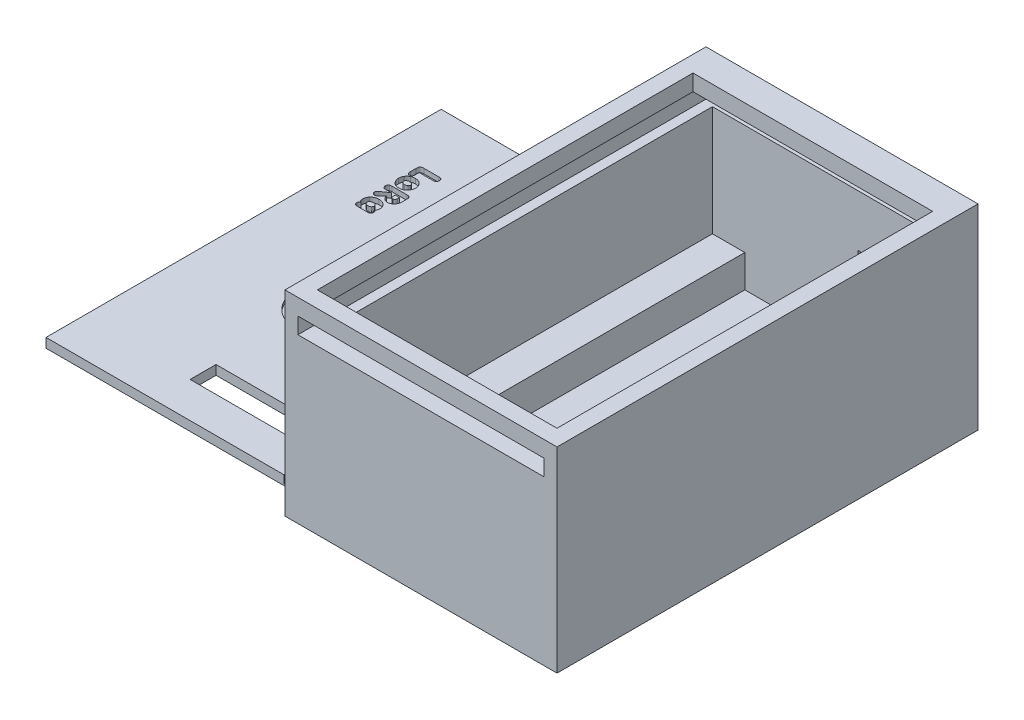
from build123d import *

# Parameters (mm, degrees)
ESQUISSE2_W              = 32
ESQUISSE2_H              = 55
BOSS_EXTRU_1_DEPTH       = 3
ESQUISSE3_W              = 55
ESQUISSE3_H              = 30
BOSS_EXTRU_2_DEPTH       = 3
ESQUISSE5_W              = 55
ESQUISSE5_H              = 30
BOSS_EXTRU_3_DEPTH       = 3
ESQUISSE6_W              = 38
ESQUISSE6_H              = 30
BOSS_EXTRU_4_DEPTH       = 3
ESQUISSE7_W              = 38
ESQUISSE7_H              = 30
BOSS_EXTRU_5_DEPTH       = 3
ESQUISSE8_W              = 3.5
ESQUISSE8_H              = 55
BOSS_EXTRU_6_DEPTH       = 5
ESQUISSE9_W              = 3.5
ESQUISSE9_H              = 55
BOSS_EXTRU_7_DEPTH       = 5
ESQUISSE12_W             = 32
ESQUISSE12_H             = 2.5
ENL_V_MAT_EXTRU_1_DEPTH  = 4
ESQUISSE13_W             = 38
ESQUISSE13_H             = 30
BOSS_EXTRU_8_DEPTH       = 2
ESQUISSE14_W             = 63
ESQUISSE14_H             = 30
BOSS_EXTRU_9_DEPTH       = 2
ESQUISSE15_W             = 40
ESQUISSE15_H             = 30
BOSS_EXTRU_10_DEPTH      = 2
ESQUISSE16_W             = 32
ESQUISSE16_H             = 2.5
ENL_V_MAT_EXTRU_2_DEPTH  = 2
ESQUISSE17_W             = 65
ESQUISSE17_H             = 30
BOSS_EXTRU_11_DEPTH      = 2
ESQUISSE18_W             = 60
ESQUISSE18_H             = 2.5
ENL_V_MAT_EXTRU_3_DEPTH  = 3
ESQUISSE19_W             = 60
ESQUISSE19_H             = 2.5
ENL_V_MAT_EXTRU_4_DEPTH  = 3
ESQUISSE20_W             = 38
ESQUISSE20_H             = 2.5
ENL_V_MAT_EXTRU_5_DEPTH  = 3
ESQUISSE22_W             = 4.144510242
ESQUISSE22_H             = 65
BOSS_EXTRU_12_DEPTH      = 0.5
ESQUISSE23_W             = 65
ESQUISSE23_H             = 2.45
BOSS_EXTRU_13_DEPTH      = 37.5
ESQUISSE24_W             = 37.5
ESQUISSE24_H             = 2.45
ENL_V_MAT_EXTRU_6_DEPTH  = 2
ESQUISSE25_W             = 4.144510242
ESQUISSE25_H             = 2
ENL_V_MAT_EXTRU_7_DEPTH  = 1.5
ESQUISSE26_W             = 42
ESQUISSE26_H             = 65
BOSS_EXTRU_14_DEPTH      = 0.5
ESQUISSE29_W             = 25
ESQUISSE29_H             = 5
BOSS_EXTRU_16_DEPTH      = 3.5
ESQUISSE31_W             = 2.5
ESQUISSE31_H             = 5
ENL_V_MAT_EXTRU_8_DEPTH  = 3.5
ESQUISSE33_W             = 11
ESQUISSE33_H             = 11
ENL_V_MAT_EXTRU_10_DEPTH = 6
ESQUISSE34_W             = 20
ESQUISSE34_H             = 4
ENL_V_MAT_EXTRU_12_DEPTH = 3.45
ESQUISSE36_R             = 5
ENL_V_MAT_EXTRU_13_DEPTH = 1.2
ESQUISSE38_W             = 32
ESQUISSE38_H             = 22
ENL_V_MAT_EXTRU_14_DEPTH = 2.5
ESQUISSE40_W             = 32
ESQUISSE40_H             = 27
ENL_V_MAT_EXTRU_15_DEPTH = 2.5
ESQUISSE42_W             = 60
ESQUISSE42_H             = 22
ENL_V_MAT_EXTRU_16_DEPTH = 2.5
ESQUISSE43_W             = 60
ESQUISSE43_H             = 22
ENL_V_MAT_EXTRU_17_DEPTH = 2.5
ESQUISSE44_W             = 3.5
ESQUISSE44_H             = 5
ENL_V_MAT_EXTRU_18_DEPTH = 5
ESQUISSE45_W             = 10
ESQUISSE45_H             = 5
ENL_V_MAT_EXTRU_19_DEPTH = 2.5
ESQUISSE47_W             = 63
ESQUISSE47_H             = 2.45
ENL_V_MAT_EXTRU_20_DEPTH = 2
ESQUISSE48_W             = 39.644510242
ESQUISSE48_H             = 2.45
ENL_V_MAT_EXTRU_21_DEPTH = 2
ESQUISSE49_W             = 81.644510242
ESQUISSE49_H             = 65
ENL_V_MAT_EXTRU_23_DEPTH = 0.25
ESQUISSE50_W             = 35.5
ESQUISSE50_H             = 61
ENL_V_MAT_EXTRU_24_DEPTH = 0.75
ESQUISSE53_W             = 2.5
ESQUISSE53_H             = 11
BOSS_EXTRU_17_DEPTH      = 1.5
ESQUISSE54_W             = 9.5
ESQUISSE54_H             = 2.5
BOSS_EXTRU_19_DEPTH      = 2
ESQUISSE55_W             = 60
ESQUISSE55_H             = 22
BOSS_EXTRU_20_DEPTH      = 1
ESQUISSE56_W             = 60
ESQUISSE56_H             = 17
BOSS_EXTRU_21_DEPTH      = 1
ESQUISSE57_W             = 2.5
ESQUISSE57_H             = 5
BOSS_EXTRU_22_DEPTH      = 3.5
ESQUISSE58_W             = 37
ESQUISSE58_H             = 2.5
BOSS_EXTRU_23_DEPTH      = 2
ESQUISSE59_W             = 61
ESQUISSE59_H             = 1.45
BOSS_EXTRU_24_DEPTH      = 1.25
ENL_V_MAT_EXTRU_27_DEPTH = 0.75


with BuildPart() as part:
    # Esquisse2 → Boss.-Extru.1 (new body)
    with BuildSketch(Plane(origin=(0, 0, 0), x_dir=(1, 0, 0), z_dir=(0, 1, 0))):
        with Locations((-55.470108058, 17.287934383)):
            Rectangle(ESQUISSE2_W, ESQUISSE2_H)
    extrude(amount=BOSS_EXTRU_1_DEPTH)

    # Esquisse3 → Boss.-Extru.2 (add)
    with BuildSketch(Plane.ZY.offset(71.470108058)):
        with Locations((-17.287934383, 15)):
            Rectangle(ESQUISSE3_W, ESQUISSE3_H)
    extrude(amount=BOSS_EXTRU_2_DEPTH)

    # Esquisse5 → Boss.-Extru.3 (add)
    with BuildSketch(Plane(origin=(-39.470108058, 0, 0), x_dir=(0, 0, -1), z_dir=(1, 0, 0))):
        with Locations((17.287934383, 15)):
            Rectangle(ESQUISSE5_W, ESQUISSE5_H)
    extrude(amount=BOSS_EXTRU_3_DEPTH)

    # Esquisse6 → Boss.-Extru.4 (add)
    with BuildSketch(Plane(origin=(0, 0, -44.787934383), x_dir=(-1, 0, 0), z_dir=(0, 0, -1))):
        with Locations((55.470108058, 15)):
            Rectangle(ESQUISSE6_W, ESQUISSE6_H)
    extrude(amount=BOSS_EXTRU_4_DEPTH)

    # Esquisse7 → Boss.-Extru.5 (add)
    with BuildSketch(Plane.XY.offset(10.212065617)):
        with Locations((-55.470108058, 15)):
            Rectangle(ESQUISSE7_W, ESQUISSE7_H)
    extrude(amount=BOSS_EXTRU_5_DEPTH)

    # Esquisse8 → Boss.-Extru.6 (add)
    with BuildSketch(Plane(origin=(0, 3, 0), x_dir=(1, 0, 0), z_dir=(0, 1, 0))):
        with Locations((-69.720108058, 17.287934383)):
            Rectangle(ESQUISSE8_W, ESQUISSE8_H)
    extrude(amount=BOSS_EXTRU_6_DEPTH)

    # Esquisse9 → Boss.-Extru.7 (add)
    with BuildSketch(Plane(origin=(0, 3, 0), x_dir=(1, 0, 0), z_dir=(0, 1, 0))):
        with Locations((-41.220108058, 17.287934383)):
            Rectangle(ESQUISSE9_W, ESQUISSE9_H)
    extrude(amount=BOSS_EXTRU_7_DEPTH)

    # Esquisse12 → Enlèv. mat.-Extru.1 (cut, through all)
    with BuildSketch(Plane(origin=(0, 0, 10.212065617), x_dir=(-1, 0, 0), z_dir=(0, 0, -1))):
        with Locations((55.470108058, 26.25)):
            Rectangle(ESQUISSE12_W, ESQUISSE12_H)
    extrude(amount=-ENL_V_MAT_EXTRU_1_DEPTH, mode=Mode.SUBTRACT)

    # Esquisse13 → Boss.-Extru.8 (add)
    with BuildSketch(Plane(origin=(0, 0, -47.787934383), x_dir=(-1, 0, 0), z_dir=(0, 0, -1))):
        with Locations((55.470108058, 15)):
            Rectangle(ESQUISSE13_W, ESQUISSE13_H)
    extrude(amount=BOSS_EXTRU_8_DEPTH)

    # Esquisse14 → Boss.-Extru.9 (add)
    with BuildSketch(Plane(origin=(-36.470108058, 0, 0), x_dir=(0, 0, -1), z_dir=(1, 0, 0))):
        with Locations((18.287934383, 15)):
            Rectangle(ESQUISSE14_W, ESQUISSE14_H)
    extrude(amount=BOSS_EXTRU_9_DEPTH)

    # Esquisse15 → Boss.-Extru.10 (add)
    with BuildSketch(Plane.XY.offset(13.212065617)):
        with Locations((-54.470108058, 15)):
            Rectangle(ESQUISSE15_W, ESQUISSE15_H)
    extrude(amount=BOSS_EXTRU_10_DEPTH)

    # Esquisse16 → Enlèv. mat.-Extru.2 (cut)
    with BuildSketch(Plane(origin=(0, 0, 13.212065617), x_dir=(-1, 0, 0), z_dir=(0, 0, -1))):
        with Locations((55.470108058, 26.25)):
            Rectangle(ESQUISSE16_W, ESQUISSE16_H)
    extrude(amount=-ENL_V_MAT_EXTRU_2_DEPTH, mode=Mode.SUBTRACT)

    # Esquisse17 → Boss.-Extru.11 (add)
    with BuildSketch(Plane.ZY.offset(74.470108058)):
        with Locations((-17.287934383, 15)):
            Rectangle(ESQUISSE17_W, ESQUISSE17_H)
    extrude(amount=BOSS_EXTRU_11_DEPTH)

    # Esquisse18 → Enlèv. mat.-Extru.3 (cut)
    with BuildSketch(Plane.ZY.offset(39.470108058)):
        with Locations((-14.787934383, 26.25)):
            Rectangle(ESQUISSE18_W, ESQUISSE18_H)
    extrude(amount=-ENL_V_MAT_EXTRU_3_DEPTH, mode=Mode.SUBTRACT)

    # Esquisse19 → Enlèv. mat.-Extru.4 (cut)
    with BuildSketch(Plane(origin=(-71.470108058, 0, 0), x_dir=(0, 0, -1), z_dir=(1, 0, 0))):
        with Locations((14.787934383, 26.25)):
            Rectangle(ESQUISSE19_W, ESQUISSE19_H)
    extrude(amount=-ENL_V_MAT_EXTRU_4_DEPTH, mode=Mode.SUBTRACT)

    # Esquisse20 → Enlèv. mat.-Extru.5 (cut)
    with BuildSketch(Plane.XY.offset(-44.787934383)):
        with Locations((-55.470108058, 26.25)):
            Rectangle(ESQUISSE20_W, ESQUISSE20_H)
    extrude(amount=-ENL_V_MAT_EXTRU_5_DEPTH, mode=Mode.SUBTRACT)



with BuildPart() as body_2:
    # Esquisse22 → Boss.-Extru.12 (new body)
    with BuildSketch(Plane.XZ):
        with Locations((-78.542363179, -17.287934383)):
            Rectangle(ESQUISSE22_W, ESQUISSE22_H)
    extrude(amount=BOSS_EXTRU_12_DEPTH)

    # Esquisse23 → Boss.-Extru.13 (add)
    with BuildSketch(Plane.ZY.offset(80.6146183)):
        with Locations((-17.287934383, 0.725)):
            Rectangle(ESQUISSE23_W, ESQUISSE23_H)
    extrude(amount=BOSS_EXTRU_13_DEPTH)

    # Esquisse24 → Enlèv. mat.-Extru.6 (cut)
    with BuildSketch(Plane.XY.offset(15.212065617)):
        with Locations((-99.3646183, 0.725)):
            Rectangle(ESQUISSE24_W, ESQUISSE24_H)
    extrude(amount=-ENL_V_MAT_EXTRU_6_DEPTH, mode=Mode.SUBTRACT)

    # Esquisse25 → Enlèv. mat.-Extru.7 (cut, through all)
    with BuildSketch(Plane(origin=(0, 0, 0), x_dir=(1, 0, 0), z_dir=(0, 1, 0))):
        with Locations((-78.542363179, -14.212065617)):
            Rectangle(ESQUISSE25_W, ESQUISSE25_H)
    extrude(amount=-ENL_V_MAT_EXTRU_7_DEPTH, mode=Mode.SUBTRACT)


with BuildPart() as part_1:
    add(part.part)

    add(body_2.part)  # Boss.-Extru.14 merges body 2
    # Esquisse26 → Boss.-Extru.14 (add, through all)
    with BuildSketch(Plane.XZ):
        with Locations((-55.470108058, -17.287934383)):
            Rectangle(ESQUISSE26_W, ESQUISSE26_H)
    extrude(amount=BOSS_EXTRU_14_DEPTH)

    # Esquisse29 → Boss.-Extru.16 (add)
    with BuildSketch(Plane(origin=(0, 0, 10.212065617), x_dir=(-1, 0, 0), z_dir=(0, 0, -1))):
        with Locations((55.470108058, 5.5)):
            Rectangle(ESQUISSE29_W, ESQUISSE29_H)
    extrude(amount=BOSS_EXTRU_16_DEPTH)

    # Esquisse31 → Enlèv. mat.-Extru.8 (cut)
    with BuildSketch(Plane.ZY.offset(42.970108058)):
        with Locations((-43.537934383, 5.5)):
            Rectangle(ESQUISSE31_W, ESQUISSE31_H)
    extrude(amount=-ENL_V_MAT_EXTRU_8_DEPTH, mode=Mode.SUBTRACT)

    # Esquisse33 → Enlèv. mat.-Extru.10 (cut, through all)
    with BuildSketch(Plane.XY.offset(-44.787934383)):
        with Locations((-44.970108058, 13.5)):
            Rectangle(ESQUISSE33_W, ESQUISSE33_H)
    extrude(amount=-ENL_V_MAT_EXTRU_10_DEPTH, mode=Mode.SUBTRACT)

    # Esquisse34 → Enlèv. mat.-Extru.12 (cut, through all)
    with BuildSketch(Plane(origin=(0, 1.95, 0), x_dir=(1, 0, 0), z_dir=(0, 1, 0))):
        with Locations((-90.6146183, -3.708093447)):
            Rectangle(ESQUISSE34_W, ESQUISSE34_H)
    extrude(amount=-ENL_V_MAT_EXTRU_12_DEPTH, mode=Mode.SUBTRACT)

    # Esquisse36 → Enlèv. mat.-Extru.13 (cut)
    with BuildSketch(Plane(origin=(-2.005651667, 1.95, -1.300827816), x_dir=(1, 0, 0), z_dir=(0, 1, 0))):
        with Locations((-97.347627811, 12.937673095)):
            Circle(ESQUISSE36_R)
    extrude(amount=-ENL_V_MAT_EXTRU_13_DEPTH, mode=Mode.SUBTRACT)

    # Esquisse38 → Enlèv. mat.-Extru.14 (cut)
    with BuildSketch(Plane(origin=(0, 0, 10.212065617), x_dir=(-1, 0, 0), z_dir=(0, 0, -1))):
        with Locations((55.470108058, 19)):
            Rectangle(ESQUISSE38_W, ESQUISSE38_H)
    extrude(amount=-ENL_V_MAT_EXTRU_14_DEPTH, mode=Mode.SUBTRACT)

    # Esquisse40 → Enlèv. mat.-Extru.15 (cut)
    with BuildSketch(Plane.XY.offset(-44.787934383)):
        with Locations((-55.470108058, 16.5)):
            Rectangle(ESQUISSE40_W, ESQUISSE40_H)
    extrude(amount=-ENL_V_MAT_EXTRU_15_DEPTH, mode=Mode.SUBTRACT)

    # Esquisse42 → Enlèv. mat.-Extru.16 (cut)
    with BuildSketch(Plane(origin=(-71.470108058, 0, 0), x_dir=(0, 0, -1), z_dir=(1, 0, 0))):
        with Locations((17.287934383, 19)):
            Rectangle(ESQUISSE42_W, ESQUISSE42_H)
    extrude(amount=-ENL_V_MAT_EXTRU_16_DEPTH, mode=Mode.SUBTRACT)

    # Esquisse43 → Enlèv. mat.-Extru.17 (cut)
    with BuildSketch(Plane.ZY.offset(39.470108058)):
        with Locations((-17.287934383, 19)):
            Rectangle(ESQUISSE43_W, ESQUISSE43_H)
    extrude(amount=-ENL_V_MAT_EXTRU_17_DEPTH, mode=Mode.SUBTRACT)

    # Esquisse44 → Enlèv. mat.-Extru.18 (cut)
    with BuildSketch(Plane(origin=(0, 0, -42.287934383), x_dir=(-1, 0, 0), z_dir=(0, 0, -1))):
        with Locations((41.220108058, 5.5)):
            Rectangle(ESQUISSE44_W, ESQUISSE44_H)
    extrude(amount=-ENL_V_MAT_EXTRU_18_DEPTH, mode=Mode.SUBTRACT)

    # Esquisse45 → Enlèv. mat.-Extru.19 (cut)
    with BuildSketch(Plane.ZY.offset(39.470108058)):
        with Locations((-42.287934383, 5.5)):
            Rectangle(ESQUISSE45_W, ESQUISSE45_H)
    extrude(amount=-ENL_V_MAT_EXTRU_19_DEPTH, mode=Mode.SUBTRACT)

    # Esquisse47 → Enlèv. mat.-Extru.20 (cut)
    with BuildSketch(Plane.ZY.offset(118.1146183)):
        with Locations((-18.287934383, 0.725)):
            Rectangle(ESQUISSE47_W, ESQUISSE47_H)
    extrude(amount=-ENL_V_MAT_EXTRU_20_DEPTH, mode=Mode.SUBTRACT)

    # Esquisse48 → Enlèv. mat.-Extru.21 (cut)
    with BuildSketch(Plane.XY.offset(13.212065617)):
        with Locations((-96.292363179, 0.725)):
            Rectangle(ESQUISSE48_W, ESQUISSE48_H)
    extrude(amount=-ENL_V_MAT_EXTRU_21_DEPTH, mode=Mode.SUBTRACT)

    # Esquisse49 → Enlèv. mat.-Extru.23 (cut)
    with BuildSketch(Plane.XZ.offset(0.5)):
        with Locations((-75.292363179, -17.287934383)):
            Rectangle(ESQUISSE49_W, ESQUISSE49_H)
    extrude(amount=-ENL_V_MAT_EXTRU_23_DEPTH, mode=Mode.SUBTRACT)

    # Esquisse50 → Enlèv. mat.-Extru.24 (cut)
    with BuildSketch(Plane(origin=(0, 1.95, 0), x_dir=(1, 0, 0), z_dir=(0, 1, 0))):
        with Locations((-98.3646183, 19.287934383)):
            Rectangle(ESQUISSE50_W, ESQUISSE50_H)
    extrude(amount=-ENL_V_MAT_EXTRU_24_DEPTH, mode=Mode.SUBTRACT)

    # Esquisse53 → Boss.-Extru.17 (add)
    with BuildSketch(Plane.ZY.offset(39.470108058)):
        with Locations((-48.537934383, 13.5)):
            Rectangle(ESQUISSE53_W, ESQUISSE53_H)
    extrude(amount=BOSS_EXTRU_17_DEPTH)

    # Esquisse54 → Boss.-Extru.19 (add)
    with BuildSketch(Plane.XZ.offset(-19)):
        with Locations((-45.720108058, -48.537934383)):
            Rectangle(ESQUISSE54_W, ESQUISSE54_H)
    extrude(amount=BOSS_EXTRU_19_DEPTH)

    # Esquisse55 → Boss.-Extru.20 (add)
    with BuildSketch(Plane.ZY.offset(36.970108058)):
        with Locations((-17.287934383, 14)):
            Rectangle(ESQUISSE55_W, ESQUISSE55_H)
    extrude(amount=BOSS_EXTRU_20_DEPTH)

    # Esquisse56 → Boss.-Extru.21 (add)
    with BuildSketch(Plane(origin=(-73.970108058, 0, 0), x_dir=(0, 0, -1), z_dir=(1, 0, 0))):
        with Locations((17.287934383, 16.5)):
            Rectangle(ESQUISSE56_W, ESQUISSE56_H)
    extrude(amount=BOSS_EXTRU_21_DEPTH)

    # Esquisse57 → Boss.-Extru.22 (add)
    with BuildSketch(Plane(origin=(-71.470108058, 0, 0), x_dir=(0, 0, -1), z_dir=(1, 0, 0))):
        with Locations((46.037934383, 5.5)):
            Rectangle(ESQUISSE57_W, ESQUISSE57_H)
    extrude(amount=BOSS_EXTRU_22_DEPTH)

    # Esquisse58 → Boss.-Extru.23 (add)
    with BuildSketch(Plane.XY.offset(-47.287934383)):
        with Locations((-55.470108058, 28.75)):
            Rectangle(ESQUISSE58_W, ESQUISSE58_H)
    extrude(amount=BOSS_EXTRU_23_DEPTH)

    # Esquisse59 → Boss.-Extru.24 (add)
    with BuildSketch(Plane.ZY.offset(116.1146183)):
        with Locations((-19.287934383, 0.475)):
            Rectangle(ESQUISSE59_W, ESQUISSE59_H)
    extrude(amount=BOSS_EXTRU_24_DEPTH)

    # Esquisse62 → Enlèv. mat.-Extru.27 (cut)
    with BuildSketch(Plane(origin=(0, 1.2, 0), x_dir=(1, 0, 0), z_dir=(0, 1, 0))):
        with BuildLine():
            Line((-110.60098691, 39.638707933), (-110.60098691, 39.0444371))
            add(Edge.make_bspline(
                [(-110.60098691, 39.0444371), (-110.601699377, 39.010618931), (-110.603019937, 38.947936782), (-110.612061779, 38.861258901), (-110.627214726, 38.788744217), (-110.645797125, 38.747928908), (-110.654216077, 38.7294371)],
                knots=[0, 0, 0, 0, 0.00010142, 0.000187982, 0.000261382, 0.000322183, 0.000322183, 0.000322183, 0.000322183], degree=3))
            add(Edge.make_bspline(
                [(-110.654216077, 38.7294371), (-110.664452385, 38.71163664), (-110.684180523, 38.677330329), (-110.720579985, 38.631953059), (-110.761473064, 38.594212332), (-110.807235748, 38.565488171), (-110.854151675, 38.542573429), (-110.902280797, 38.527841372), (-110.949719645, 38.516344758), (-110.981786673, 38.515486681), (-110.997653577, 38.5150621)],
                knots=[0, 0, 0, 0, 6.1527e-05, 0.000118579, 0.000173809, 0.000227609, 0.000280119, 0.000329927, 0.00037841, 0.000425896, 0.000425896, 0.000425896, 0.000425896], degree=3))
            add(Edge.make_bspline(
                [(-110.997653577, 38.5150621), (-111.013246752, 38.515910426), (-111.044941313, 38.517634726), (-111.092897033, 38.52726695), (-111.140978127, 38.544439934), (-111.189013988, 38.567529985), (-111.23532068, 38.597715971), (-111.275896019, 38.637328197), (-111.313491979, 38.682725962), (-111.332666309, 38.717880009), (-111.34254941, 38.7359996)],
                knots=[0, 0, 0, 0, 4.6809e-05, 9.5143e-05, 0.000146107, 0.00019959, 0.0002548, 0.000311022, 0.000369099, 0.000430876, 0.000430876, 0.000430876, 0.000430876], degree=3))
            add(Edge.make_bspline(
                [(-111.34254941, 38.7359996), (-111.350748978, 38.754743109), (-111.368951169, 38.796351761), (-111.382798262, 38.870413448), (-111.393565101, 38.959035056), (-111.394055418, 39.023482428), (-111.394320244, 39.058291267)],
                knots=[0, 0, 0, 0, 6.1202e-05, 0.000135863, 0.00022468, 0.000328992, 0.000328992, 0.000328992, 0.000328992], degree=3))
            Line((-111.394320244, 39.058291267), (-111.394320244, 39.9522496))
            add(Edge.make_bspline(
                [(-111.394320244, 39.9522496), (-111.394124373, 39.984336133), (-111.393760523, 40.043940178), (-111.38910407, 40.126289651), (-111.380263812, 40.194659147), (-111.369471319, 40.251898475), (-111.350354402, 40.301037927), (-111.326509385, 40.347620361), (-111.293708571, 40.391798121), (-111.255828575, 40.434275164), (-111.213354082, 40.472178942), (-111.169144439, 40.504888523), (-111.122752383, 40.529011711), (-111.073269807, 40.546944796), (-111.016007814, 40.5581418), (-110.947093046, 40.566770421), (-110.864278663, 40.571482882), (-110.804429152, 40.571846379), (-110.772341077, 40.572041267)],
                knots=[0, 0, 0, 0, 9.6261e-05, 0.000178815, 0.00024719, 0.000303108, 0.000352948, 0.000404806, 0.000459649, 0.000517478, 0.000575308, 0.000630151, 0.000682009, 0.000731598, 0.000787516, 0.000856614, 0.000939895, 0.001036156, 0.001036156, 0.001036156, 0.001036156], degree=3))
            Line((-110.772341077, 40.572041267), (-108.49442441, 40.572041267))
            add(Edge.make_bspline(
                [(-108.49442441, 40.572041267), (-108.458893301, 40.571471942), (-108.392499924, 40.570408102), (-108.300277181, 40.559453931), (-108.221663101, 40.542902566), (-108.176756986, 40.522909016), (-108.156091077, 40.513707933)],
                knots=[0, 0, 0, 0, 0.000106521, 0.000199044, 0.000278457, 0.000346159, 0.000346159, 0.000346159, 0.000346159], degree=3))
            add(Edge.make_bspline(
                [(-108.156091077, 40.513707933), (-108.140714592, 40.504426232), (-108.109536758, 40.485606367), (-108.067846373, 40.448691672), (-108.031349922, 40.404295665), (-107.999784787, 40.354453757), (-107.973425399, 40.30078831), (-107.954442628, 40.24469735), (-107.943077853, 40.18701386), (-107.941686005, 40.148202169), (-107.94098691, 40.128707933)],
                knots=[0, 0, 0, 0, 5.38e-05, 0.000109087, 0.000166037, 0.000225709, 0.000285713, 0.000344974, 0.000402891, 0.000461338, 0.000461338, 0.000461338, 0.000461338], degree=3))
            add(Edge.make_bspline(
                [(-107.94098691, 40.128707933), (-107.941855607, 40.105800623), (-107.943578086, 40.060379255), (-107.956545737, 39.993558243), (-107.976731222, 39.928651742), (-108.006104433, 39.868169171), (-108.03844453, 39.812779731), (-108.074243588, 39.766273653), (-108.112284035, 39.729149996), (-108.140914076, 39.711879349), (-108.154632744, 39.703603767)],
                knots=[0, 0, 0, 0, 6.8681e-05, 0.000136183, 0.00020352, 0.000272019, 0.000337421, 0.000395617, 0.000447715, 0.000495647, 0.000495647, 0.000495647, 0.000495647], degree=3))
            add(Edge.make_bspline(
                [(-108.154632744, 39.703603767), (-108.176737053, 39.69342604), (-108.223521791, 39.671884436), (-108.303219763, 39.652603302), (-108.393458634, 39.641242055), (-108.457196414, 39.639582382), (-108.490778577, 39.638707933)],
                knots=[0, 0, 0, 0, 7.2862e-05, 0.000154216, 0.000244659, 0.000345379, 0.000345379, 0.000345379, 0.000345379], degree=3))
            Line((-108.490778577, 39.638707933), (-110.60098691, 39.638707933))
        make_face()
        with BuildLine():
            add(Edge.make_bspline(
                [(-108.781716077, 37.3075621), (-108.782285192, 37.276675519), (-108.783416757, 37.215264134), (-108.792249272, 37.123849387), (-108.807573844, 37.034462961), (-108.828886822, 36.946713821), (-108.856401576, 36.861154865), (-108.890439824, 36.777536283), (-108.929509878, 36.695330943), (-108.960672016, 36.642820774), (-108.976403577, 36.6163121)],
                knots=[0, 0, 0, 0, 9.265e-05, 0.000184215, 0.0002752, 0.00036451, 0.000454904, 0.000544541, 0.000635204, 0.000727636, 0.000727636, 0.000727636, 0.000727636], degree=3))
            add(Edge.make_bspline(
                [(-108.976403577, 36.6163121), (-108.994046878, 36.5890949), (-109.028777486, 36.535518197), (-109.086202687, 36.460154696), (-109.146258384, 36.389923457), (-109.210846308, 36.326549762), (-109.278052809, 36.268442931), (-109.349062717, 36.216610034), (-109.423360995, 36.170381518), (-109.475423323, 36.144387738), (-109.501403577, 36.131416267)],
                knots=[0, 0, 0, 0, 9.7275e-05, 0.000191484, 0.000284019, 0.000374251, 0.000462672, 0.000550324, 0.000637742, 0.000724819, 0.000724819, 0.000724819, 0.000724819], degree=3))
            add(Edge.make_bspline(
                [(-109.501403577, 36.131416267), (-109.549321333, 36.110689395), (-109.644932884, 36.069332525), (-109.796628381, 36.03021885), (-109.951991928, 36.002658625), (-110.057631188, 36.000033711), (-110.11098691, 35.998707933)],
                knots=[0, 0, 0, 0, 0.000156391, 0.00031205, 0.000468726, 0.000628615, 0.000628615, 0.000628615, 0.000628615], degree=3))
            add(Edge.make_bspline(
                [(-110.11098691, 35.998707933), (-110.15552712, 35.999523522), (-110.243477643, 36.00113401), (-110.372448762, 36.018833731), (-110.496718247, 36.045140715), (-110.615108678, 36.084440898), (-110.728850513, 36.133219721), (-110.837059501, 36.193285684), (-110.940144817, 36.264405058), (-111.003497178, 36.319405046), (-111.035570244, 36.3472496)],
                knots=[0, 0, 0, 0, 0.000133535, 0.000263683, 0.000389831, 0.000514117, 0.000637244, 0.000760618, 0.00088481, 0.001012153, 0.001012153, 0.001012153, 0.001012153], degree=3))
            add(Edge.make_bspline(
                [(-111.035570244, 36.3472496), (-111.06706042, 36.378822379), (-111.13110544, 36.443035397), (-111.212827934, 36.555809917), (-111.287500306, 36.680655867), (-111.327252068, 36.771611016), (-111.347653577, 36.818291267)],
                knots=[0, 0, 0, 0, 0.000133589, 0.000271694, 0.000416507, 0.000569187, 0.000569187, 0.000569187, 0.000569187], degree=3))
            add(Edge.make_bspline(
                [(-111.347653577, 36.818291267), (-111.362082852, 36.856677781), (-111.3908783, 36.933282941), (-111.419493715, 37.053193601), (-111.437755227, 37.17623008), (-111.43990242, 37.259613845), (-111.44098691, 37.301728767)],
                knots=[0, 0, 0, 0, 0.000122918, 0.000245299, 0.000369042, 0.000495323, 0.000495323, 0.000495323, 0.000495323], degree=3))
            add(Edge.make_bspline(
                [(-111.44098691, 37.301728767), (-111.440521703, 37.331413098), (-111.439596484, 37.390450195), (-111.429232683, 37.478033184), (-111.415302713, 37.564464592), (-111.393664343, 37.649115325), (-111.366994165, 37.732668603), (-111.33281777, 37.814082663), (-111.294705463, 37.895025139), (-111.263993904, 37.946547326), (-111.24848691, 37.9725621)],
                knots=[0, 0, 0, 0, 8.9006e-05, 0.000177018, 0.000264287, 0.000351473, 0.000438867, 0.000527153, 0.000616186, 0.00070699, 0.00070699, 0.00070699, 0.00070699], degree=3))
            add(Edge.make_bspline(
                [(-111.24848691, 37.9725621), (-111.232067555, 37.997842673), (-111.199409305, 38.048125967), (-111.144495037, 38.118749225), (-111.085422371, 38.184965397), (-111.02078815, 38.24505559), (-110.95303533, 38.301991686), (-110.879913854, 38.352486151), (-110.803090793, 38.39932703), (-110.74876572, 38.425345086), (-110.72129941, 38.4384996)],
                knots=[0, 0, 0, 0, 9.0399e-05, 0.000179804, 0.000268094, 0.000356299, 0.000444338, 0.000533344, 0.000622631, 0.000713937, 0.000713937, 0.000713937, 0.000713937], degree=3))
            add(Edge.make_bspline(
                [(-110.72129941, 38.4384996), (-110.674052414, 38.458087183), (-110.57845043, 38.497721698), (-110.425086109, 38.537331297), (-110.262663298, 38.560797385), (-110.151172682, 38.563826919), (-110.094216077, 38.5653746)],
                knots=[0, 0, 0, 0, 0.000153285, 0.000310164, 0.000473712, 0.000644525, 0.000644525, 0.000644525, 0.000644525], degree=3))
            add(Edge.make_bspline(
                [(-110.094216077, 38.5653746), (-110.051396418, 38.564114484), (-109.965950667, 38.561599949), (-109.839152011, 38.545643808), (-109.714838571, 38.517379287), (-109.594121038, 38.479040496), (-109.478639901, 38.431575343), (-109.371386136, 38.374279354), (-109.272875363, 38.308566628), (-109.214996315, 38.256438724), (-109.186403577, 38.2306871)],
                knots=[0, 0, 0, 0, 0.000128466, 0.000256351, 0.000382657, 0.000510413, 0.000635942, 0.000756641, 0.00087475, 0.000990062, 0.000990062, 0.000990062, 0.000990062], degree=3))
            add(Edge.make_bspline(
                [(-109.186403577, 38.2306871), (-109.154603327, 38.198985332), (-109.092023433, 38.136599241), (-109.011154863, 38.033400403), (-108.941034062, 37.926298884), (-108.88467361, 37.812771846), (-108.840011302, 37.694034257), (-108.807057397, 37.570024736), (-108.787133072, 37.440409778), (-108.783542449, 37.352352475), (-108.781716077, 37.3075621)],
                knots=[0, 0, 0, 0, 0.000134596, 0.000264872, 0.000392495, 0.000518041, 0.000644263, 0.00077249, 0.000902325, 0.001036731, 0.001036731, 0.001036731, 0.001036731], degree=3))
        make_face()
        with BuildLine():
            add(Edge.make_bspline(
                [(-109.574320244, 37.3184996), (-109.575943315, 37.340430771), (-109.579265653, 37.385322676), (-109.609799638, 37.449454675), (-109.656783192, 37.510213075), (-109.719803551, 37.567704278), (-109.797653598, 37.617819737), (-109.889734337, 37.653906544), (-109.993387686, 37.674732467), (-110.066409529, 37.67734688), (-110.10442441, 37.678707933)],
                knots=[0, 0, 0, 0, 6.5483e-05, 0.00013404, 0.000208999, 0.00029518, 0.00038863, 0.000485172, 0.000590137, 0.00070412, 0.00070412, 0.00070412, 0.00070412], degree=3))
            add(Edge.make_bspline(
                [(-110.10442441, 37.678707933), (-110.142427793, 37.677732952), (-110.214269722, 37.675889838), (-110.315180686, 37.658476579), (-110.403368255, 37.629820411), (-110.452723949, 37.598755074), (-110.47629941, 37.583916267)],
                knots=[0, 0, 0, 0, 0.000113899, 0.000215317, 0.000306404, 0.000389702, 0.000389702, 0.000389702, 0.000389702], degree=3))
            add(Edge.make_bspline(
                [(-110.47629941, 37.583916267), (-110.502302551, 37.564282608), (-110.550870064, 37.527611731), (-110.605155129, 37.460647299), (-110.640948409, 37.390784971), (-110.64545386, 37.341723801), (-110.647653577, 37.317770433)],
                knots=[0, 0, 0, 0, 9.7376e-05, 0.000181874, 0.000256893, 0.000328463, 0.000328463, 0.000328463, 0.000328463], degree=3))
            add(Edge.make_bspline(
                [(-110.647653577, 37.317770433), (-110.646232124, 37.291295717), (-110.643402852, 37.238600231), (-110.616693613, 37.163161651), (-110.576419232, 37.091685264), (-110.537823506, 37.051824041), (-110.51786191, 37.031207933)],
                knots=[0, 0, 0, 0, 7.9157e-05, 0.000157556, 0.000237598, 0.000323343, 0.000323343, 0.000323343, 0.000323343], degree=3))
            add(Edge.make_bspline(
                [(-110.51786191, 37.031207933), (-110.505278489, 37.019413938), (-110.480179536, 36.995889579), (-110.436898051, 36.967041678), (-110.39120135, 36.940995893), (-110.341230237, 36.921034353), (-110.288656581, 36.904575087), (-110.232330242, 36.894164627), (-110.172943026, 36.886309313), (-110.131918253, 36.885690385), (-110.11098691, 36.8853746)],
                knots=[0, 0, 0, 0, 5.1653e-05, 0.000103027, 0.000155577, 0.000209199, 0.000264096, 0.000320581, 0.000380816, 0.000443562, 0.000443562, 0.000443562, 0.000443562], degree=3))
            add(Edge.make_bspline(
                [(-110.11098691, 36.8853746), (-110.090296414, 36.885673776), (-110.049993174, 36.886256545), (-109.991359153, 36.894295022), (-109.9355143, 36.90458971), (-109.883106284, 36.92087239), (-109.833517469, 36.941171075), (-109.787848944, 36.967192783), (-109.743926934, 36.996055451), (-109.717933958, 37.019432645), (-109.704841077, 37.031207933)],
                knots=[0, 0, 0, 0, 6.2018e-05, 0.000120805, 0.000177291, 0.000232187, 0.000285136, 0.000337686, 0.000389662, 0.000442415, 0.000442415, 0.000442415, 0.000442415], degree=3))
            add(Edge.make_bspline(
                [(-109.704841077, 37.031207933), (-109.6851934, 37.05137374), (-109.646775811, 37.090804441), (-109.605846836, 37.161497517), (-109.579271785, 37.2379018), (-109.57599136, 37.291298315), (-109.574320244, 37.3184996)],
                knots=[0, 0, 0, 0, 8.4171e-05, 0.000164581, 0.000242979, 0.000324388, 0.000324388, 0.000324388, 0.000324388], degree=3))
        make_face(mode=Mode.SUBTRACT)
        with BuildLine():
            Line((-110.051195244, 34.7853746), (-110.88973691, 34.7853746))
            add(Edge.make_bspline(
                [(-110.88973691, 34.7853746), (-110.923807538, 34.786227919), (-110.988036154, 34.787836563), (-111.078742082, 34.799299299), (-111.158271822, 34.818406633), (-111.204756498, 34.840080273), (-111.22661191, 34.850270433)],
                knots=[0, 0, 0, 0, 0.000102177, 0.00019262, 0.000273974, 0.000346165, 0.000346165, 0.000346165, 0.000346165], degree=3))
            add(Edge.make_bspline(
                [(-111.22661191, 34.850270433), (-111.240326266, 34.858548635), (-111.268947307, 34.87582475), (-111.307062645, 34.91290291), (-111.342476508, 34.959548078), (-111.376242568, 35.013974968), (-111.405152191, 35.074644298), (-111.425451523, 35.139481083), (-111.438438093, 35.206559691), (-111.440129453, 35.252224306), (-111.44098691, 35.2753746)],
                knots=[0, 0, 0, 0, 4.7931e-05, 0.00010003, 0.000158226, 0.000223384, 0.000291883, 0.000359219, 0.000426721, 0.00049613, 0.00049613, 0.00049613, 0.00049613], degree=3))
            add(Edge.make_bspline(
                [(-111.44098691, 35.2753746), (-111.440270239, 35.295105093), (-111.438843456, 35.334385504), (-111.427831187, 35.392429296), (-111.408201392, 35.448176286), (-111.383056235, 35.502008189), (-111.351569534, 35.551664061), (-111.314617795, 35.59512269), (-111.273875626, 35.632516397), (-111.24276273, 35.65114233), (-111.227341077, 35.6603746)],
                knots=[0, 0, 0, 0, 5.9175e-05, 0.000117808, 0.000176378, 0.000236067, 0.000295739, 0.00035213, 0.000406871, 0.000460672, 0.000460672, 0.000460672, 0.000460672], degree=3))
            add(Edge.make_bspline(
                [(-111.227341077, 35.6603746), (-111.206427025, 35.66956394), (-111.161224197, 35.689425424), (-111.082203112, 35.706221046), (-110.989706866, 35.717018881), (-110.923077544, 35.718120518), (-110.88754941, 35.718707933)],
                knots=[0, 0, 0, 0, 6.8379e-05, 0.000147791, 0.000241039, 0.000347559, 0.000347559, 0.000347559, 0.000347559], degree=3))
            Line((-110.88754941, 35.718707933), (-108.584841077, 35.718707933))
            add(Edge.make_bspline(
                [(-108.584841077, 35.718707933), (-108.557373125, 35.718645965), (-108.506550235, 35.718531307), (-108.436729464, 35.71581727), (-108.379251718, 35.710945476), (-108.318380917, 35.701852836), (-108.248996861, 35.67863335), (-108.201382008, 35.647002762), (-108.176507744, 35.630478767)],
                knots=[0, 0, 0, 0, 8.2399e-05, 0.00015246, 0.000209563, 0.000255356, 0.000336984, 0.00042627, 0.00042627, 0.00042627, 0.00042627], degree=3))
            add(Edge.make_bspline(
                [(-108.176507744, 35.630478767), (-108.161313285, 35.618235498), (-108.131493129, 35.594207252), (-108.093343182, 35.551532302), (-108.059950661, 35.50577518), (-108.033966803, 35.454536954), (-108.012442718, 35.400005937), (-107.998148516, 35.34086557), (-107.989216936, 35.278081324), (-107.988182939, 35.234816158), (-107.987653577, 35.212666267)],
                knots=[0, 0, 0, 0, 5.8447e-05, 0.000114707, 0.000171159, 0.000227908, 0.000286541, 0.00034667, 0.000409986, 0.000476404, 0.000476404, 0.000476404, 0.000476404], degree=3))
            Line((-107.987653577, 35.212666267), (-107.987653577, 35.120791267))
            Line((-107.987653577, 35.120791267), (-107.987653577, 34.449228767))
            add(Edge.make_bspline(
                [(-107.987653577, 34.449228767), (-107.988504355, 34.404477067), (-107.990158475, 34.317468842), (-108.002701415, 34.190227281), (-108.02353835, 34.070255237), (-108.05293688, 33.957157858), (-108.089512613, 33.851069439), (-108.136349918, 33.752497935), (-108.190153913, 33.66023064), (-108.233708137, 33.604646941), (-108.255257744, 33.577145433)],
                knots=[0, 0, 0, 0, 0.000134238, 0.000260991, 0.000383148, 0.000499166, 0.000611244, 0.000719213, 0.000826132, 0.00093084, 0.00093084, 0.00093084, 0.00093084], degree=3))
            add(Edge.make_bspline(
                [(-108.255257744, 33.577145433), (-108.28182984, 33.54685855), (-108.333864863, 33.487549015), (-108.421687553, 33.410793319), (-108.514024016, 33.345052684), (-108.612439, 33.291451419), (-108.71630658, 33.249979764), (-108.82525531, 33.21963013), (-108.939849335, 33.201942358), (-109.018147846, 33.199800177), (-109.058070244, 33.198707933)],
                knots=[0, 0, 0, 0, 0.00012076, 0.00023648, 0.000348963, 0.00046023, 0.000571802, 0.000683783, 0.000798871, 0.000918597, 0.000918597, 0.000918597, 0.000918597], degree=3))
            add(Edge.make_bspline(
                [(-109.058070244, 33.198707933), (-109.09288397, 33.19942279), (-109.161340333, 33.200828457), (-109.261512652, 33.215647656), (-109.357330902, 33.236614901), (-109.44815602, 33.268677548), (-109.533871734, 33.309355153), (-109.615129862, 33.358769689), (-109.691411454, 33.417253022), (-109.737609143, 33.462416178), (-109.76098691, 33.485270433)],
                knots=[0, 0, 0, 0, 0.000104363, 0.000205215, 0.000303208, 0.000398218, 0.000493458, 0.000587373, 0.000683047, 0.000781059, 0.000781059, 0.000781059, 0.000781059], degree=3))
            add(Edge.make_bspline(
                [(-109.76098691, 33.485270433), (-109.775125418, 33.500831469), (-109.803885089, 33.532484757), (-109.842057779, 33.584837486), (-109.876598191, 33.641470266), (-109.917625679, 33.72310144), (-109.959991724, 33.834463138), (-109.97979174, 33.928504232), (-109.989945244, 33.976728767)],
                knots=[0, 0, 0, 0, 6.3038e-05, 0.000128228, 0.000194007, 0.000261835, 0.000402139, 0.000549816, 0.000549816, 0.000549816, 0.000549816], degree=3))
            Line((-109.989945244, 33.976728767), (-110.64692441, 33.3547496))
            add(Edge.make_bspline(
                [(-110.64692441, 33.3547496), (-110.665442274, 33.338228512), (-110.700763327, 33.306716116), (-110.7545295, 33.265206789), (-110.804555658, 33.229165702), (-110.852144999, 33.19963832), (-110.897424023, 33.176523041), (-110.940388118, 33.160931054), (-110.980261196, 33.149163799), (-111.006329436, 33.14815083), (-111.01879941, 33.147666267)],
                knots=[0, 0, 0, 0, 7.4425e-05, 0.000141959, 0.000203667, 0.000259318, 0.000309863, 0.000355777, 0.000396454, 0.000433755, 0.000433755, 0.000433755, 0.000433755], degree=3))
            add(Edge.make_bspline(
                [(-111.01879941, 33.147666267), (-111.04526624, 33.149090516), (-111.09794603, 33.151925352), (-111.174220895, 33.178846508), (-111.246432689, 33.220214682), (-111.312838852, 33.276878196), (-111.369951, 33.346148127), (-111.4112661, 33.427491366), (-111.437053299, 33.518231085), (-111.439646688, 33.582070753), (-111.44098691, 33.6150621)],
                knots=[0, 0, 0, 0, 7.9157e-05, 0.000157556, 0.000239858, 0.000327806, 0.000417999, 0.000507354, 0.000599702, 0.000698466, 0.000698466, 0.000698466, 0.000698466], degree=3))
            add(Edge.make_bspline(
                [(-111.44098691, 33.6150621), (-111.440258133, 33.63309783), (-111.438827919, 33.668492677), (-111.428482113, 33.719583819), (-111.411741043, 33.767235069), (-111.386321059, 33.812143592), (-111.351290813, 33.85637342), (-111.307199172, 33.904203507), (-111.251273273, 33.954657245), (-111.209969543, 33.989038216), (-111.187966077, 34.007353767)],
                knots=[0, 0, 0, 0, 5.4081e-05, 0.000106134, 0.000155723, 0.000205016, 0.000260144, 0.000324645, 0.000399986, 0.000485879, 0.000485879, 0.000485879, 0.000485879], degree=3))
            Line((-111.187966077, 34.007353767), (-110.051195244, 34.7853746))
        make_face()
        with BuildLine():
            Line((-109.431403577, 34.7853746), (-109.431403577, 34.4288121))
            add(Edge.make_bspline(
                [(-109.431403577, 34.4288121), (-109.430394749, 34.403420498), (-109.428456983, 34.354648125), (-109.410702356, 34.286029913), (-109.381875058, 34.22564878), (-109.341386646, 34.175470201), (-109.293236382, 34.135063999), (-109.239282233, 34.106300173), (-109.180920677, 34.088692329), (-109.140588086, 34.08649404), (-109.12004941, 34.0853746)],
                knots=[0, 0, 0, 0, 7.6057e-05, 0.000146092, 0.000210987, 0.000275328, 0.000337973, 0.000398322, 0.000457618, 0.000519145, 0.000519145, 0.000519145, 0.000519145], degree=3))
            add(Edge.make_bspline(
                [(-109.12004941, 34.0853746), (-109.097060365, 34.086608929), (-109.052198634, 34.089017647), (-108.987737729, 34.10884134), (-108.928987887, 34.141504308), (-108.877818675, 34.187045295), (-108.834445735, 34.241213394), (-108.803835925, 34.303770981), (-108.783599891, 34.372148336), (-108.781874589, 34.420154376), (-108.78098691, 34.444853767)],
                knots=[0, 0, 0, 0, 6.8855e-05, 0.000134367, 0.000200303, 0.000269034, 0.000338615, 0.000407095, 0.000476806, 0.000550682, 0.000550682, 0.000550682, 0.000550682], degree=3))
            Line((-108.78098691, 34.444853767), (-108.78098691, 34.7853746))
            Line((-108.78098691, 34.7853746), (-109.431403577, 34.7853746))
        make_face(mode=Mode.SUBTRACT)
        with BuildLine():
            add(Edge.make_bspline(
                [(-111.12817441, 31.1759996), (-111.152748972, 31.187255459), (-111.201209198, 31.209451643), (-111.265008534, 31.258494498), (-111.319782973, 31.318310835), (-111.364292595, 31.390224611), (-111.39915604, 31.472389326), (-111.423771818, 31.564662158), (-111.438147066, 31.666519503), (-111.44001533, 31.737652911), (-111.44098691, 31.774645433)],
                knots=[0, 0, 0, 0, 8.0872e-05, 0.000159476, 0.000239476, 0.000323028, 0.000411879, 0.000506336, 0.000608734, 0.000719685, 0.000719685, 0.000719685, 0.000719685], degree=3))
            add(Edge.make_bspline(
                [(-111.44098691, 31.774645433), (-111.440135394, 31.809196564), (-111.438444139, 31.87782087), (-111.425248433, 31.979225565), (-111.402374613, 32.077513398), (-111.370933664, 32.172722056), (-111.330605592, 32.26496548), (-111.281621616, 32.354065955), (-111.223647858, 32.440345683), (-111.178747835, 32.493992667), (-111.155882744, 32.5213121)],
                knots=[0, 0, 0, 0, 0.000103634, 0.000205835, 0.000306123, 0.000405966, 0.000506213, 0.000607703, 0.000710642, 0.000817459, 0.000817459, 0.000817459, 0.000817459], degree=3))
            add(Edge.make_bspline(
                [(-111.155882744, 32.5213121), (-111.122907341, 32.556907184), (-111.057856423, 32.627125974), (-110.946639513, 32.717344683), (-110.827437425, 32.794336689), (-110.699074895, 32.85757294), (-110.561292434, 32.905507094), (-110.415297893, 32.940608439), (-110.260070607, 32.961070102), (-110.153825261, 32.96391509), (-110.099320244, 32.9653746)],
                knots=[0, 0, 0, 0, 0.000145413, 0.000286859, 0.000428238, 0.000570418, 0.000715016, 0.00086499, 0.001020193, 0.001183689, 0.001183689, 0.001183689, 0.001183689], degree=3))
            add(Edge.make_bspline(
                [(-110.099320244, 32.9653746), (-110.050638738, 32.964448532), (-109.955316098, 32.962635209), (-109.815760914, 32.942661603), (-109.682708145, 32.912288826), (-109.555698212, 32.870374672), (-109.435980311, 32.814094159), (-109.322874797, 32.746206404), (-109.215796757, 32.666291322), (-109.151269874, 32.604417914), (-109.118591077, 32.573082933)],
                knots=[0, 0, 0, 0, 0.00014595, 0.000285783, 0.000421979, 0.000555025, 0.000686164, 0.000817968, 0.000950239, 0.00108596, 0.00108596, 0.00108596, 0.00108596], degree=3))
            add(Edge.make_bspline(
                [(-109.118591077, 32.573082933), (-109.09158118, 32.544122546), (-109.038764425, 32.487491688), (-108.969604807, 32.396358138), (-108.911872958, 32.301872492), (-108.863997106, 32.20432404), (-108.826654731, 32.103701217), (-108.800438371, 31.999799312), (-108.783663524, 31.893075582), (-108.781884124, 31.820645484), (-108.78098691, 31.7841246)],
                knots=[0, 0, 0, 0, 0.000118749, 0.000232209, 0.000342508, 0.00045045, 0.000557726, 0.000663837, 0.000771497, 0.000880991, 0.000880991, 0.000880991, 0.000880991], degree=3))
            add(Edge.make_bspline(
                [(-108.78098691, 31.7841246), (-108.781625652, 31.749062497), (-108.78286484, 31.681040347), (-108.79816441, 31.582886091), (-108.820982732, 31.491681871), (-108.853688276, 31.408545394), (-108.895025747, 31.333703253), (-108.946842844, 31.26999281), (-109.006396599, 31.214829319), (-109.052861859, 31.188049355), (-109.07629941, 31.174541267)],
                knots=[0, 0, 0, 0, 0.000105091, 0.000203882, 0.000297261, 0.000386627, 0.000471192, 0.000552614, 0.000632123, 0.000713048, 0.000713048, 0.000713048, 0.000713048], degree=3))
            add(Edge.make_bspline(
                [(-109.07629941, 31.174541267), (-109.054423684, 31.169207883), (-109.011904931, 31.158841653), (-108.953424155, 31.131206115), (-108.902140258, 31.095082765), (-108.859010688, 31.050042252), (-108.82363108, 30.998283405), (-108.798491182, 30.939372266), (-108.783926809, 30.874587207), (-108.781984376, 30.829476858), (-108.78098691, 30.8063121)],
                knots=[0, 0, 0, 0, 6.7408e-05, 0.000131017, 0.000192725, 0.000254605, 0.000317097, 0.00037981, 0.000445613, 0.000515071, 0.000515071, 0.000515071, 0.000515071], degree=3))
            add(Edge.make_bspline(
                [(-108.78098691, 30.8063121), (-108.782452484, 30.773831349), (-108.785281931, 30.711123766), (-108.809134145, 30.622092196), (-108.848323158, 30.542556128), (-108.903287664, 30.47538555), (-108.967446482, 30.421177528), (-109.037715563, 30.381017959), (-109.113141977, 30.35679519), (-109.165332114, 30.353629166), (-109.191507744, 30.352041267)],
                knots=[0, 0, 0, 0, 9.731e-05, 0.000187868, 0.000274283, 0.000361399, 0.000446265, 0.000524951, 0.0006029, 0.000681332, 0.000681332, 0.000681332, 0.000681332], degree=3))
            Line((-109.191507744, 30.352041267), (-110.92911191, 30.352041267))
            add(Edge.make_bspline(
                [(-110.92911191, 30.352041267), (-110.959644292, 30.353304715), (-111.019411655, 30.355777925), (-111.105790452, 30.379426783), (-111.185446853, 30.417941047), (-111.257797788, 30.470239194), (-111.319483947, 30.536421537), (-111.362787039, 30.617626807), (-111.390127972, 30.710515633), (-111.392877651, 30.776695582), (-111.394320244, 30.811416267)],
                knots=[0, 0, 0, 0, 9.1437e-05, 0.000178989, 0.000266391, 0.000355651, 0.00044546, 0.000535195, 0.000629345, 0.000733256, 0.000733256, 0.000733256, 0.000733256], degree=3))
            add(Edge.make_bspline(
                [(-111.394320244, 30.811416267), (-111.393506712, 30.834326834), (-111.391944494, 30.878321774), (-111.37935544, 30.94100265), (-111.359140345, 30.99747223), (-111.329517089, 31.047332741), (-111.290909138, 31.089840692), (-111.244786518, 31.126362238), (-111.189958255, 31.155876631), (-111.14933202, 31.169108577), (-111.12817441, 31.1759996)],
                knots=[0, 0, 0, 0, 6.8681e-05, 0.000131888, 0.000190946, 0.000247844, 0.000304644, 0.000362267, 0.000423604, 0.000490262, 0.000490262, 0.000490262, 0.000490262], degree=3))
        make_face()
        with BuildLine():
            add(Edge.make_bspline(
                [(-109.574320244, 31.684228767), (-109.575882881, 31.710497532), (-109.579025249, 31.763322396), (-109.608771422, 31.838791739), (-109.655301768, 31.909812536), (-109.697788518, 31.94928419), (-109.720153577, 31.9700621)],
                knots=[0, 0, 0, 0, 7.851e-05, 0.000157879, 0.000239987, 0.000331249, 0.000331249, 0.000331249, 0.000331249], degree=3))
            add(Edge.make_bspline(
                [(-109.720153577, 31.9700621), (-109.744357294, 31.986930394), (-109.794537155, 32.021902241), (-109.885637661, 32.05530462), (-109.990225397, 32.075718464), (-110.064937132, 32.077674247), (-110.10442441, 32.078707933)],
                knots=[0, 0, 0, 0, 8.8193e-05, 0.000182844, 0.00028838, 0.000406687, 0.000406687, 0.000406687, 0.000406687], degree=3))
            add(Edge.make_bspline(
                [(-110.10442441, 32.078707933), (-110.145372534, 32.07768724), (-110.222742219, 32.075758684), (-110.330869257, 32.0552734), (-110.425049731, 32.022371767), (-110.476435821, 31.986529973), (-110.501091077, 31.969332933)],
                knots=[0, 0, 0, 0, 0.000122676, 0.00023179, 0.000329166, 0.000418981, 0.000418981, 0.000418981, 0.000418981], degree=3))
            add(Edge.make_bspline(
                [(-110.501091077, 31.969332933), (-110.523469427, 31.949332936), (-110.566579556, 31.910804517), (-110.613492211, 31.839795159), (-110.642173744, 31.762169261), (-110.645808927, 31.708046954), (-110.647653577, 31.680582933)],
                knots=[0, 0, 0, 0, 8.972e-05, 0.000172839, 0.000252642, 0.000334857, 0.000334857, 0.000334857, 0.000334857], degree=3))
            add(Edge.make_bspline(
                [(-110.647653577, 31.680582933), (-110.645940862, 31.649478396), (-110.642616011, 31.589095939), (-110.613232713, 31.502951864), (-110.565764509, 31.425875854), (-110.499904312, 31.359409765), (-110.419179848, 31.305141565), (-110.325103798, 31.266773071), (-110.219597779, 31.242843376), (-110.145394757, 31.24012744), (-110.10661191, 31.238707933)],
                knots=[0, 0, 0, 0, 9.3088e-05, 0.00018071, 0.000269751, 0.000362565, 0.000459234, 0.000559578, 0.000665717, 0.000781931, 0.000781931, 0.000781931, 0.000781931], degree=3))
            add(Edge.make_bspline(
                [(-110.10661191, 31.238707933), (-110.08569315, 31.239110774), (-110.044962639, 31.239895138), (-109.985666433, 31.246469527), (-109.930182621, 31.257616871), (-109.877826803, 31.27164773), (-109.829795373, 31.291847997), (-109.784598861, 31.314913441), (-109.743744059, 31.343540439), (-109.719213707, 31.365575037), (-109.707028577, 31.376520433)],
                knots=[0, 0, 0, 0, 6.2746e-05, 0.000122172, 0.000178658, 0.000232444, 0.00028444, 0.000334668, 0.000384428, 0.000433543, 0.000433543, 0.000433543, 0.000433543], degree=3))
            add(Edge.make_bspline(
                [(-109.707028577, 31.376520433), (-109.686743027, 31.397828155), (-109.64701719, 31.439555743), (-109.606434592, 31.515577331), (-109.579002934, 31.597290217), (-109.575903745, 31.654829584), (-109.574320244, 31.684228767)],
                knots=[0, 0, 0, 0, 8.787e-05, 0.000172078, 0.000256249, 0.000344185, 0.000344185, 0.000344185, 0.000344185], degree=3))
        make_face(mode=Mode.SUBTRACT)
    extrude(amount=-ENL_V_MAT_EXTRU_27_DEPTH, mode=Mode.SUBTRACT)


solid = part_1.part
